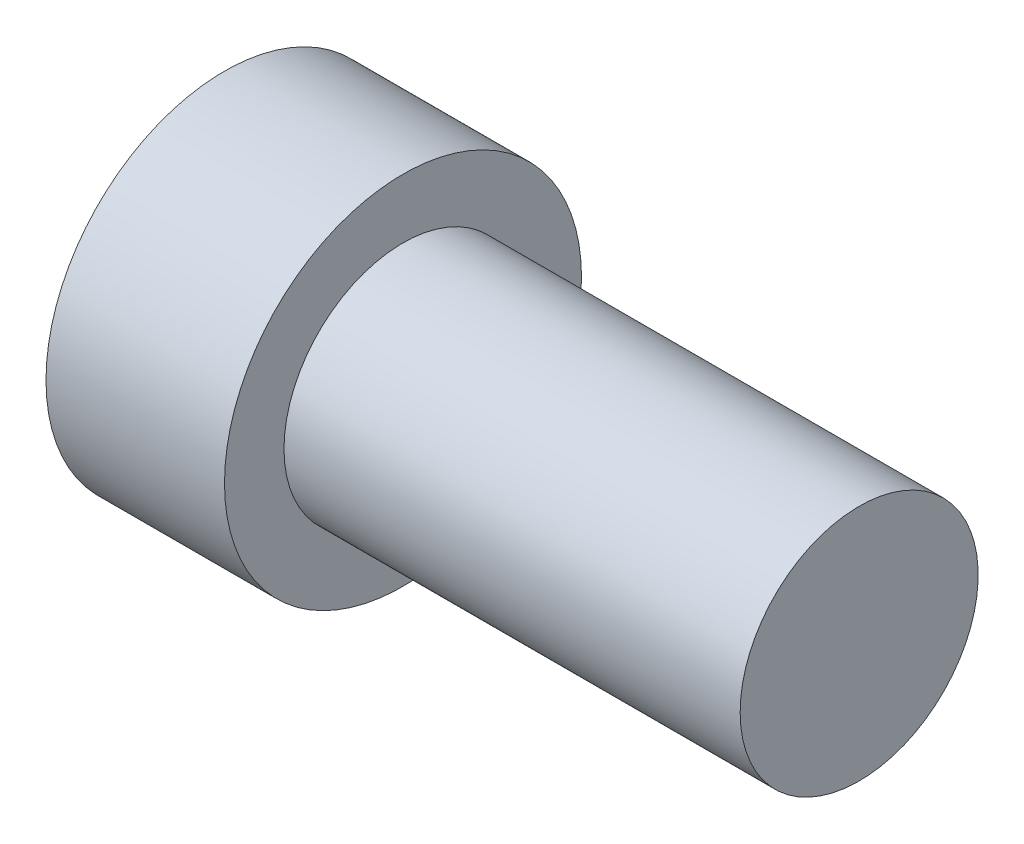
from build123d import *

# Parameters (mm, degrees)
SKIZZE4_R                       = 2.5
SCHNITT_LINEAR_AUSTRAGEN1_DEPTH = 20.5


with BuildPart() as part:
    # Skizze3 → Rotation1 (revolve)
    with BuildSketch(Plane(origin=(0, 0, 0), x_dir=(1, 0, 0), z_dir=(0, 1, 0))):
        Polygon((0, 0), (32, 0), (32, 6), (9, 6), (9, 9), (0, 9), align=None)
    revolve(axis=Axis((0, 0, 0), (1, 0, 0)))

    # Skizze4 → Schnitt-Linear austragen1 (cut)
    with BuildSketch(Plane.ZY):
        Circle(SKIZZE4_R)
    extrude(amount=-SCHNITT_LINEAR_AUSTRAGEN1_DEPTH, mode=Mode.SUBTRACT)


solid = part.part
